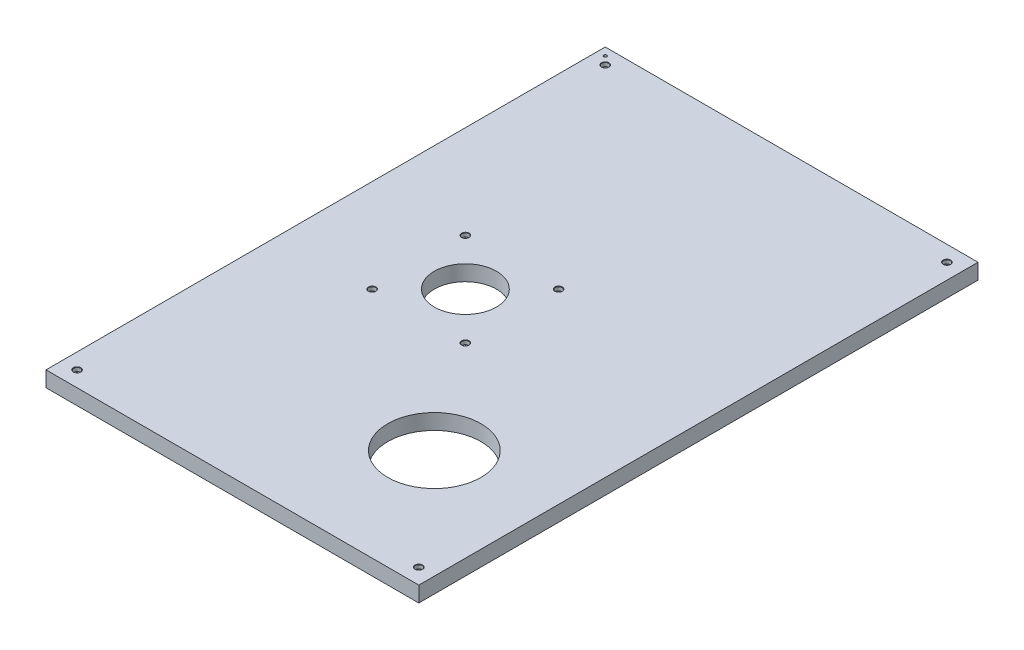
from build123d import *

# Parameters (mm, degrees)
SKETCH2_W                                     = 609.6
SKETCH2_H                                     = 914.4
BOSS_EXTRUDE1_DEPTH                           = 25.4
F_1_4_20_TAPPED_HOLE1_D                       = 5.1054
SKETCH46_R                                    = 76.2
CUT_EXTRUDE3_DEPTH                            = 26.4
SKETCH47_R                                    = 50.8
CUT_EXTRUDE4_DEPTH                            = 26.4
CBORE_FOR_1_4_SOCKET_HEAD_CAP_SCREW1_AT_COUNT = 2
CBORE_FOR_1_4_SOCKET_HEAD_CAP_SCREW1_AT_PITCH = 558.8
CBORE_FOR_1_4_SOCKET_HEAD_CAP_SCREW1_2_COUNT  = 2
CBORE_FOR_1_4_SOCKET_HEAD_CAP_SCREW1_2_PITCH  = 1028.621601951
CBORE_FOR_1_4_SOCKET_HEAD_CAP_SCREW1_3_COUNT  = 2
CBORE_FOR_1_4_SOCKET_HEAD_CAP_SCREW1_3_PITCH  = 863.6
CBORE_FOR_1_4_SOCKET_HEAD_CAP_SCREW1_4_COUNT  = 2
CBORE_FOR_1_4_SOCKET_HEAD_CAP_SCREW1_4_PITCH  = 523.634414453
CBORE_FOR_1_4_SOCKET_HEAD_CAP_SCREW1_5_COUNT  = 2
CBORE_FOR_1_4_SOCKET_HEAD_CAP_SCREW1_5_PITCH  = 579.765780294
CBORE_FOR_1_4_SOCKET_HEAD_CAP_SCREW1_6_COUNT  = 2
CBORE_FOR_1_4_SOCKET_HEAD_CAP_SCREW1_6_PITCH  = 452.234142895
CBORE_FOR_1_4_SOCKET_HEAD_CAP_SCREW1_7_COUNT  = 2
CBORE_FOR_1_4_SOCKET_HEAD_CAP_SCREW1_7_PITCH  = 377.598146182


with BuildPart() as part:
    # Sketch2 → Boss-Extrude1 (new body)
    with BuildSketch(Plane(origin=(0, 0, 0), x_dir=(1, 0, 0), z_dir=(0, 1, 0))):
        with Locations((659.0884662, -7.96825605)):
            Rectangle(SKETCH2_W, SKETCH2_H)
    extrude(amount=BOSS_EXTRUDE1_DEPTH)

    # 1/4-20 Tapped Hole1 (through all)
    with Locations(Plane(origin=(0, 25.4, 0), x_dir=(1, 0, 0), z_dir=(0, 1, 0))):
        with Locations((366.9884662, 436.53174395)):
            Hole(F_1_4_20_TAPPED_HOLE1_D / 2)

    # Sketch46 → Cut-Extrude3 (cut, through all)
    with BuildSketch(Plane(origin=(0, 25.4, 0), x_dir=(1, 0, 0), z_dir=(0, 1, 0))):
        with Locations((786.0884662, -261.96825605)):
            Circle(SKETCH46_R)
    extrude(amount=-CUT_EXTRUDE3_DEPTH, mode=Mode.SUBTRACT)

    # Sketch47 → Cut-Extrude4 (cut, through all)
    with BuildSketch(Plane(origin=(0, 25.4, 0), x_dir=(1, 0, 0), z_dir=(0, 1, 0))):
        with Locations((582.8884662, -7.96825605)):
            Circle(SKETCH47_R)
    extrude(amount=-CUT_EXTRUDE4_DEPTH, mode=Mode.SUBTRACT)

    # Sketch51 → CBORE for 1/4 Socket Head Cap Screw1 (revolve, cut)
    with BuildSketch(Plane(origin=(379.6884662, 25.4, -423.83174395), x_dir=(0, 0, 1), z_dir=(1, 0, 0))):
        Polygon((0, 0), (0, 25.4), (3.3782, 25.4), (3.3782, 6.35), (5.55625, 6.35), (5.55625, 0.635), (6.19125, 0), align=None)
    cbore_for_1_4_socket_head_cap_screw1 = revolve(axis=Axis((379.6884662, 31.75, -423.83174395), (0, -1, 0)), mode=Mode.SUBTRACT)

    # CBORE for 1/4 Socket Head Cap Screw1 at: CBORE for 1/4 Socket Head Cap Screw1 ×2
    with Locations(*[(i * CBORE_FOR_1_4_SOCKET_HEAD_CAP_SCREW1_AT_PITCH, 0, 0) for i in range(1, CBORE_FOR_1_4_SOCKET_HEAD_CAP_SCREW1_AT_COUNT)]):
        add(cbore_for_1_4_socket_head_cap_screw1, mode=Mode.SUBTRACT)

    # CBORE for 1_4 Socket Head Cap Screw1 2: CBORE for 1/4 Socket Head Cap Screw1 ×2
    with Locations(*[Vector(0.543251278, 0, 0.839570157) * (i * CBORE_FOR_1_4_SOCKET_HEAD_CAP_SCREW1_2_PITCH) for i in range(1, CBORE_FOR_1_4_SOCKET_HEAD_CAP_SCREW1_2_COUNT)]):
        add(cbore_for_1_4_socket_head_cap_screw1, mode=Mode.SUBTRACT)

    # CBORE for 1_4 Socket Head Cap Screw1 3: CBORE for 1/4 Socket Head Cap Screw1 ×2
    with Locations(*[(0, 0, i * CBORE_FOR_1_4_SOCKET_HEAD_CAP_SCREW1_3_PITCH) for i in range(1, CBORE_FOR_1_4_SOCKET_HEAD_CAP_SCREW1_3_COUNT)]):
        add(cbore_for_1_4_socket_head_cap_screw1, mode=Mode.SUBTRACT)

    # CBORE for 1_4 Socket Head Cap Screw1 4: CBORE for 1/4 Socket Head Cap Screw1 ×2
    with Locations(*[Vector(0.242535625, 0, 0.9701425) * (i * CBORE_FOR_1_4_SOCKET_HEAD_CAP_SCREW1_4_PITCH) for i in range(1, CBORE_FOR_1_4_SOCKET_HEAD_CAP_SCREW1_4_COUNT)]):
        add(cbore_for_1_4_socket_head_cap_screw1, mode=Mode.SUBTRACT)

    # CBORE for 1_4 Socket Head Cap Screw1 5: CBORE for 1/4 Socket Head Cap Screw1 ×2
    with Locations(*[Vector(0.48191875, 0, 0.876215909) * (i * CBORE_FOR_1_4_SOCKET_HEAD_CAP_SCREW1_5_PITCH) for i in range(1, CBORE_FOR_1_4_SOCKET_HEAD_CAP_SCREW1_5_COUNT)]):
        add(cbore_for_1_4_socket_head_cap_screw1, mode=Mode.SUBTRACT)

    # CBORE for 1_4 Socket Head Cap Screw1 6: CBORE for 1/4 Socket Head Cap Screw1 ×2
    with Locations(*[Vector(0.617821552, 0, 0.786318339) * (i * CBORE_FOR_1_4_SOCKET_HEAD_CAP_SCREW1_6_PITCH) for i in range(1, CBORE_FOR_1_4_SOCKET_HEAD_CAP_SCREW1_6_COUNT)]):
        add(cbore_for_1_4_socket_head_cap_screw1, mode=Mode.SUBTRACT)

    # CBORE for 1_4 Socket Head Cap Screw1 7: CBORE for 1/4 Socket Head Cap Screw1 ×2
    with Locations(*[Vector(0.336336397, 0, 0.941741912) * (i * CBORE_FOR_1_4_SOCKET_HEAD_CAP_SCREW1_7_PITCH) for i in range(1, CBORE_FOR_1_4_SOCKET_HEAD_CAP_SCREW1_7_COUNT)]):
        add(cbore_for_1_4_socket_head_cap_screw1, mode=Mode.SUBTRACT)


solid = part.part
